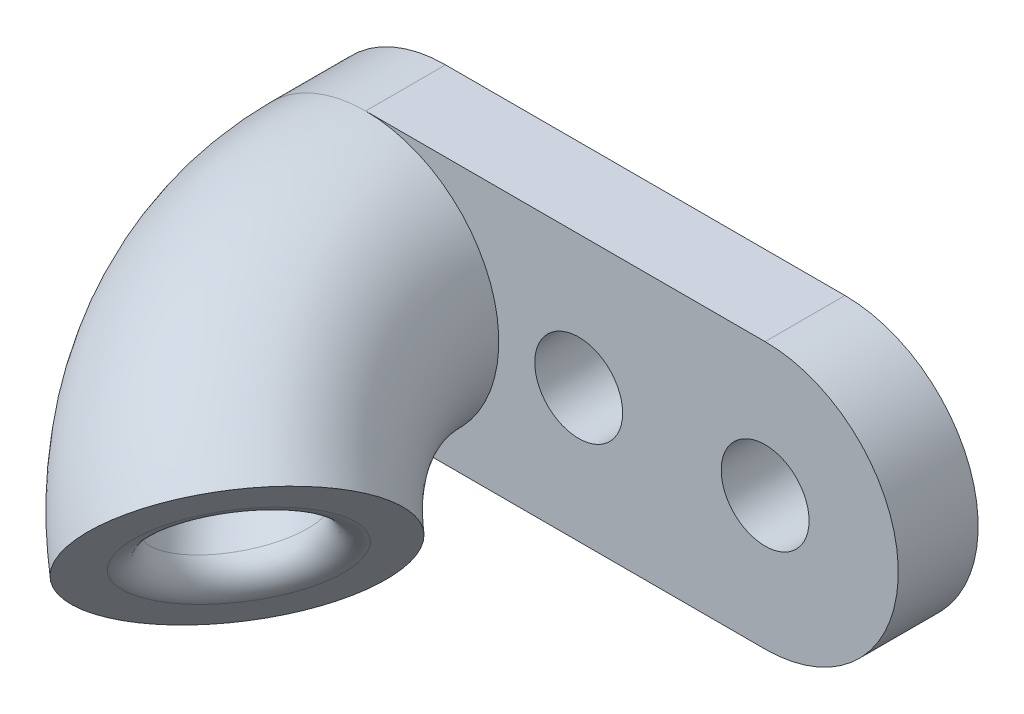
from build123d import *

# Parameters (mm, degrees)
SKETCH_1_R          = 2.5
EXTRUDE_1_DEPTH     = 3
SKETCH_4_R          = 5
SKETCH_4_R_2        = 2.5
SKETCH_5_R          = 1.65
CUT_EXTRUDE_1_DEPTH = 25.960601113
FILLET_1_R          = 1


with BuildPart() as part:
    # ｽｹｯﾁ1 → ﾎﾞｽ - 押し出し1 (new body)
    with BuildSketch(Plane.XY):
        with BuildLine():
            Line((0, 5), (15, 5))
            ThreePointArc((15, 5), (20, 0), (15, -5))
            Line((15, -5), (0, -5))
            ThreePointArc((0, -5), (-5, 0), (0, 5))
        make_face()
        Circle(SKETCH_1_R, mode=Mode.SUBTRACT)
    extrude(amount=-EXTRUDE_1_DEPTH)

    # ｽｲｰﾌﾟ1: sweep along a path in ｽｹｯﾁ6
    with BuildLine(Plane(origin=(0, 0, 0), x_dir=(0, 0, 1), z_dir=(0.6427876096865379, 0.7660444431189792, 0))) as sweep_1_path:
        ThreePointArc((0, 0), (5, 1.339745962), (8.660254038, 5))
    # ｽｹｯﾁ4 → ｽｲｰﾌﾟ1 (sweep)
    with BuildSketch(Plane.XY):
        Circle(SKETCH_4_R)
        Circle(SKETCH_4_R_2, mode=Mode.SUBTRACT)
    sweep(path=sweep_1_path.line)

    # ｽｹｯﾁ5 → ｶｯﾄ - 押し出し1 (cut, through all)
    with BuildSketch(Plane.XY):
        with Locations((8, 0)):
            Circle(SKETCH_5_R)
        with Locations((15, 0)):
            Circle(SKETCH_5_R)
    extrude(amount=-CUT_EXTRUDE_1_DEPTH, mode=Mode.SUBTRACT)

    # ﾌｨﾚｯﾄ1
    fillet_1_edges = [part.edges().sort_by_distance(p)[0] for p in [
        (2.063752327, -3.829442894, 10.318788908),
    ]]
    fillet(fillet_1_edges, radius=FILLET_1_R)


solid = part.part
